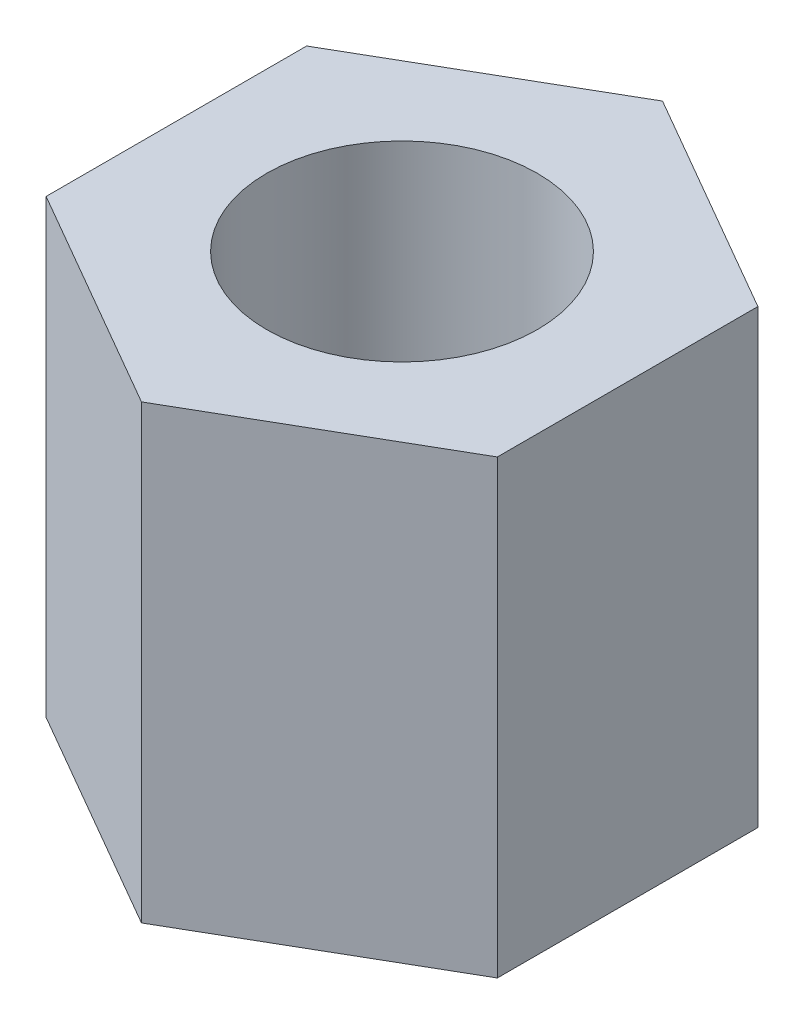
from build123d import *

# Parameters (mm, degrees)
SKETCH1_R           = 1.905
BOSS_EXTRUDE1_DEPTH = 6.35


with BuildPart() as part:
    # Sketch1 → Boss-Extrude1 (new body)
    with BuildSketch(Plane(origin=(0, 0, 0), x_dir=(1, 0, 0), z_dir=(0, 1, 0))):
        Polygon((0, -3.666174209), (3.175, -1.833087105), (3.175, 1.833087105), (0, 3.666174209), (-3.175, 1.833087105), (-3.175, -1.833087105), align=None)
        Circle(SKETCH1_R, mode=Mode.SUBTRACT)
    extrude(amount=BOSS_EXTRUDE1_DEPTH)


solid = part.part
